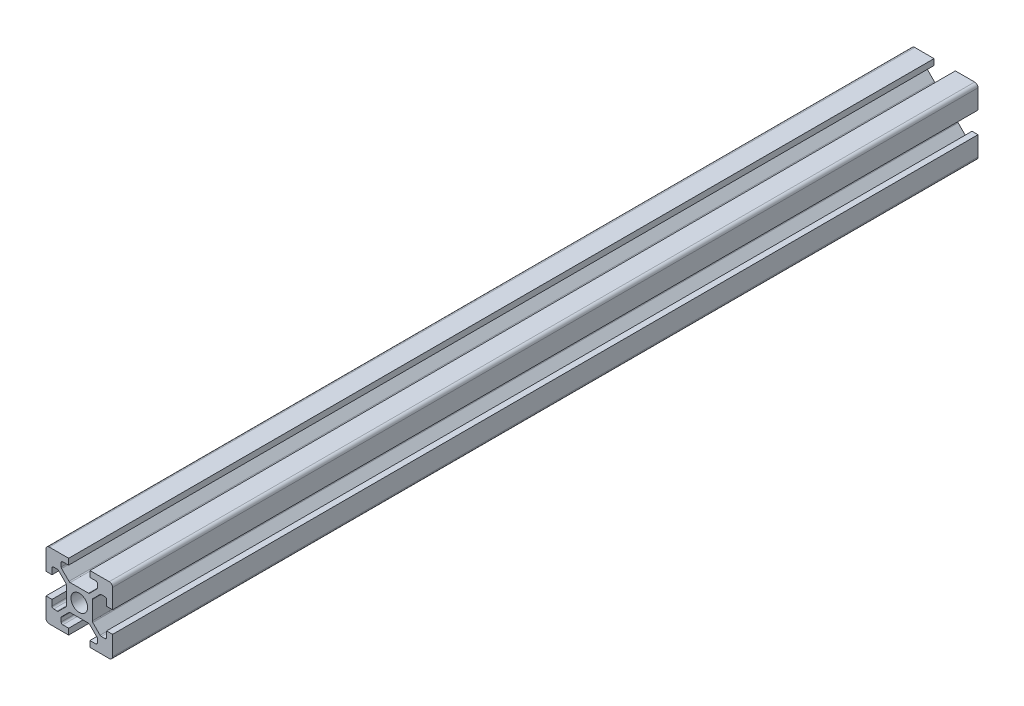
from build123d import *

# Parameters (mm, degrees)
SKETCH1_R           = 2.5
BOSS_EXTRUDE1_DEPTH = 300
FILLET1_R           = 1
FILLET2_R           = 0.5
FILLET3_R           = 0.5
FILLET4_R           = 0.5
FILLET5_R           = 0.5
SKETCH4_W           = 85.130466005
SKETCH4_H           = 76.492403511
CUT_EXTRUDE4_DEPTH  = 40


with BuildPart() as part:
    # Sketch1 → Boss-Extrude1 (new body)
    with BuildSketch(Plane.XY):
        Polygon((13.2, 0), (13.2, 1.8), (15.45, 1.8), (15.45, 3.6), (12.95, 6.1), (7.05, 6.1), (4.55, 3.6), (4.55, 1.8), (6.8, 1.8), (6.8, 0), (0, 0), (0, 6.8), (1.8, 6.8), (1.8, 4.55), (3.6, 4.55), (6.1, 7.05), (6.1, 12.95), (3.6, 15.45), (1.8, 15.45), (1.8, 13.2), (0, 13.2), (0, 20), (6.8, 20), (6.8, 18.2), (4.55, 18.2), (4.55, 16.4), (7.05, 13.9), (12.95, 13.9), (15.45, 16.4), (15.45, 18.2), (13.2, 18.2), (13.2, 20), (20, 20), (20, 13.2), (18.2, 13.2), (18.2, 15.45), (16.4, 15.45), (13.9, 12.95), (13.9, 7.05), (16.4, 4.55), (18.2, 4.55), (18.2, 6.8), (20, 6.8), (20, 0), align=None)
        with Locations((10, 10)):
            Circle(SKETCH1_R, mode=Mode.SUBTRACT)
    extrude(amount=BOSS_EXTRUDE1_DEPTH)

    # Fillet1
    fillet1_edges = [part.edges().sort_by_distance(p)[0] for p in [
        (0, 0, 150),
        (0, 20, 150),
        (20, 20, 150),
        (20, 0, 150),
    ]]
    fillet(fillet1_edges, radius=FILLET1_R)

    # Fillet2
    fillet2_edges = [part.edges().sort_by_distance(p)[0] for p in [
        (4.55, 18.2, 150),
        (4.55, 16.4, 150),
        (7.05, 13.9, 150),
        (12.95, 13.9, 150),
        (15.45, 16.4, 150),
        (15.45, 18.2, 150),
    ]]
    fillet(fillet2_edges, radius=FILLET2_R)

    # Fillet3
    fillet3_edges = [part.edges().sort_by_distance(p)[0] for p in [
        (18.2, 15.45, 150),
        (16.4, 15.45, 150),
        (13.9, 12.95, 150),
        (13.9, 7.05, 150),
        (16.4, 4.55, 150),
        (18.2, 4.55, 150),
    ]]
    fillet(fillet3_edges, radius=FILLET3_R)

    # Fillet4
    fillet4_edges = [part.edges().sort_by_distance(p)[0] for p in [
        (1.8, 4.55, 150),
        (3.6, 4.55, 150),
        (6.1, 7.05, 150),
        (6.1, 12.95, 150),
        (3.6, 15.45, 150),
        (1.8, 15.45, 150),
    ]]
    fillet(fillet4_edges, radius=FILLET4_R)

    # Fillet5
    fillet5_edges = [part.edges().sort_by_distance(p)[0] for p in [
        (15.45, 1.8, 150),
        (15.45, 3.6, 150),
        (12.95, 6.1, 150),
        (7.05, 6.1, 150),
        (4.55, 3.6, 150),
        (4.55, 1.8, 150),
    ]]
    fillet(fillet5_edges, radius=FILLET5_R)

    # Sketch4 → Cut-Extrude4 (cut)
    with BuildSketch(Plane(origin=(0, 0, 0), x_dir=(-1, 0, 0), z_dir=(0, 0, -1))):
        with Locations((13.179490335, -10.50880322)):
            Rectangle(SKETCH4_W, SKETCH4_H)
    extrude(amount=-CUT_EXTRUDE4_DEPTH, mode=Mode.SUBTRACT)


solid = part.part
